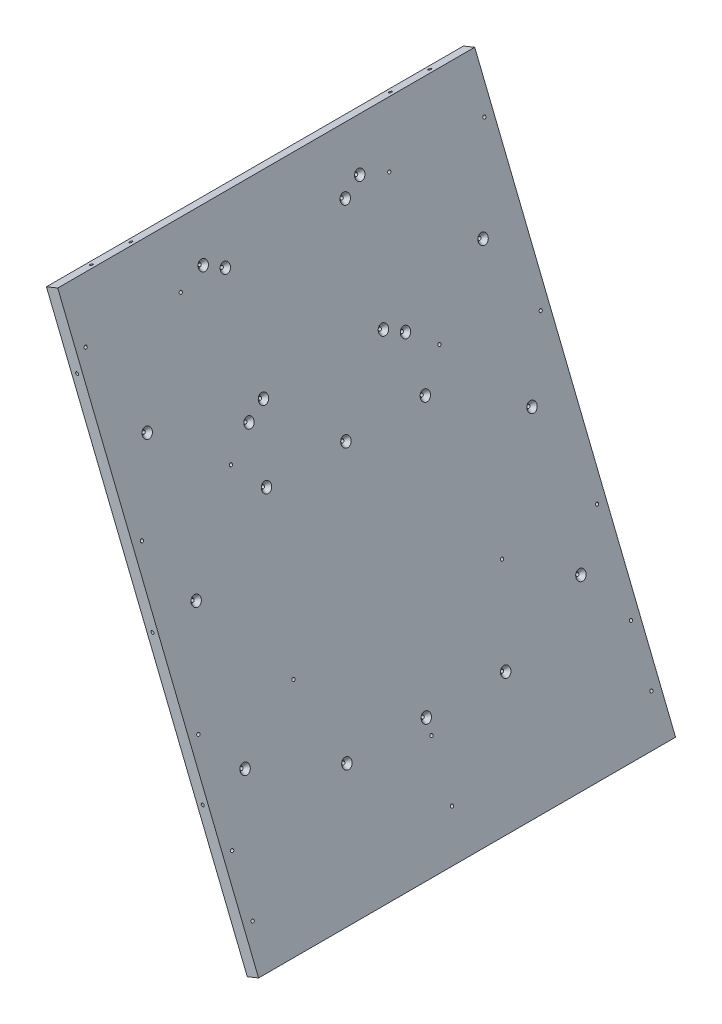
from build123d import *

# Parameters (mm, degrees)
BOSS_EXTRUDE1_DEPTH      = 217.3
BOSS_EXTRUDE1_DEPTH_BACK = 217.3
HOLE1_D                  = 3.175
HOLE1_DEPTH              = 31.75
HOLE1_CSINK_D            = 10.16
HOLE1_CSINK_ANGLE        = 82
HOLE1_TIP                = 0.953866
HOLE2_D                  = 3.175
HOLE2_DEPTH              = 31.75
HOLE2_CSINK_D            = 10.16
HOLE2_CSINK_ANGLE        = 82
HOLE2_TIP                = 0.953866
HOLE3_D                  = 3.175
HOLE3_DEPTH              = 31.75
HOLE3_CSINK_D            = 10.16
HOLE3_CSINK_ANGLE        = 82
HOLE3_TIP                = 0.953866
HOLE4_D                  = 3.175
HOLE4_DEPTH              = 31.75
HOLE4_CSINK_D            = 10.16
HOLE4_CSINK_ANGLE        = 82
HOLE4_TIP                = 0.953866
HOLE5_D                  = 3.175
HOLE5_DEPTH              = 38.1
HOLE5_CSINK_D            = 10.16
HOLE5_CSINK_ANGLE        = 82
HOLE5_TIP                = 0.953866


with BuildPart() as part:
    # Sketch1 → Boss-Extrude1 (new body, two sides)
    with BuildSketch(Plane.XY) as boss_extrude1_sk:
        Polygon((274.67986, -487.291663), (65.349696, 30.818675), (53.574461, 26.061171), (262.904625, -492.049167), align=None)
    extrude(amount=BOSS_EXTRUDE1_DEPTH)
    extrude(boss_extrude1_sk.sketch, amount=-BOSS_EXTRUDE1_DEPTH_BACK)

    # Hole1
    with Locations(Plane(origin=(361.532828, -736.162535, 0), x_dir=(0, 0, 1), z_dir=(-0.927184, -0.374607, 0))):
        with Locations((207.775, 613.051809), (-207.775, 613.051809), (-207.775, 456.277103), (-207.775, 769.826514), (-108.65, 456.277103), (-108.65, 630.126514), (-108.65, 769.826514), (-207.775, 362.200879), (-207.775, 305.102738), (0, 305.102738), (0, 362.200879), (207.775, 305.102738), (207.775, 362.200879), (108.65, 769.826514), (108.65, 630.126514), (108.65, 456.277103), (207.775, 769.826514), (207.775, 456.277103)):
            CounterSinkHole(HOLE1_D / 2, HOLE1_CSINK_D / 2, depth=HOLE1_DEPTH, counter_sink_angle=HOLE1_CSINK_ANGLE)
            with Locations((0, 0, -(HOLE1_DEPTH + HOLE1_TIP / 2))):  # 118° drill point
                Cone(0, HOLE1_D / 2, HOLE1_TIP, mode=Mode.SUBTRACT)

    # Hole2
    with Locations(Plane(origin=(723.49836, -589.918968, -230), x_dir=(-1, 0, 0), z_dir=(0, 0, -1))):
        with Locations((637.870011, 553.595098), (52.960475, 241.752641), (47.697836, 183.489834), (434.459075, 134.806235), (453.103621, 177.188748), (478.414399, 275.292666), (488.870508, 435.756795), (636.071224, 609.11142), (609.449424, 543.220155), (559.371199, 359.303721), (507.038658, 229.776137)):
            CounterSinkHole(HOLE2_D / 2, HOLE2_CSINK_D / 2, depth=HOLE2_DEPTH, counter_sink_angle=HOLE2_CSINK_ANGLE)
            with Locations((0, 0, -(HOLE2_DEPTH + HOLE2_TIP / 2))):  # 118° drill point
                Cone(0, HOLE2_D / 2, HOLE2_TIP, mode=Mode.SUBTRACT)

    # Hole3
    with Locations(Plane(origin=(723.49836, -589.918968, 230), x_dir=(1, 0, 0), z_dir=(0, 0, 1))):
        with Locations((-507.038658, 229.776137), (-559.371199, 359.303721), (-637.870011, 553.595098), (-636.071224, 609.11142), (-609.449424, 543.220155), (-488.870508, 435.756795), (-478.414399, 275.292666), (-453.103621, 177.188748), (-434.459075, 134.806235), (-52.960475, 241.752641), (-47.697836, 183.489834)):
            CounterSinkHole(HOLE3_D / 2, HOLE3_CSINK_D / 2, depth=HOLE3_DEPTH, counter_sink_angle=HOLE3_CSINK_ANGLE)
            with Locations((0, 0, -(HOLE3_DEPTH + HOLE3_TIP / 2))):  # 118° drill point
                Cone(0, HOLE3_D / 2, HOLE3_TIP, mode=Mode.SUBTRACT)

    # Hole4
    with Locations(Plane(origin=(373.308063, -731.405032, 0), x_dir=(0, 0, -1), z_dir=(0.927184, 0.374607, 0))):
        with Locations((175, 685.961004), (175, 549.83726), (175, 413.713515), (81.55, 779.649723), (81.55, 652.344646), (62.5, 662.953402), (62.5, 769.040967), (-62.5, 769.040967), (-62.5, 662.953402), (-81.55, 652.344646), (-81.55, 779.649723), (-175, 413.713515), (-175, 549.83726), (-175, 685.961004), (-82.7375, 600.38462), (0, 600.38462), (82.7375, 600.38462), (0, 376.73777), (-82.7375, 376.73777), (82.7375, 376.73777)):
            CounterSinkHole(HOLE4_D / 2, HOLE4_CSINK_D / 2, depth=HOLE4_DEPTH, counter_sink_angle=HOLE4_CSINK_ANGLE)
            with Locations((0, 0, -(HOLE4_DEPTH + HOLE4_TIP / 2))):  # 118° drill point
                Cone(0, HOLE4_D / 2, HOLE4_TIP, mode=Mode.SUBTRACT)

    # Hole5
    with Locations(Plane(origin=(410.782489, 184.079973, 0), x_dir=(0, 0, -1), z_dir=(-0.374607, 0.927184, 0))):
        with Locations((-108.65, 332.891935), (108.65, 332.891935), (207.775, 332.891935), (175, 448.336333), (135.266667, 384.042402), (176.283333, 384.042402), (-175, 448.336333), (-135.266667, 384.042402), (-176.283333, 384.042402), (-207.775, 332.891935)):
            CounterSinkHole(HOLE5_D / 2, HOLE5_CSINK_D / 2, depth=HOLE5_DEPTH, counter_sink_angle=HOLE5_CSINK_ANGLE)
            with Locations((0, 0, -(HOLE5_DEPTH + HOLE5_TIP / 2))):  # 118° drill point
                Cone(0, HOLE5_D / 2, HOLE5_TIP, mode=Mode.SUBTRACT)


solid = part.part
